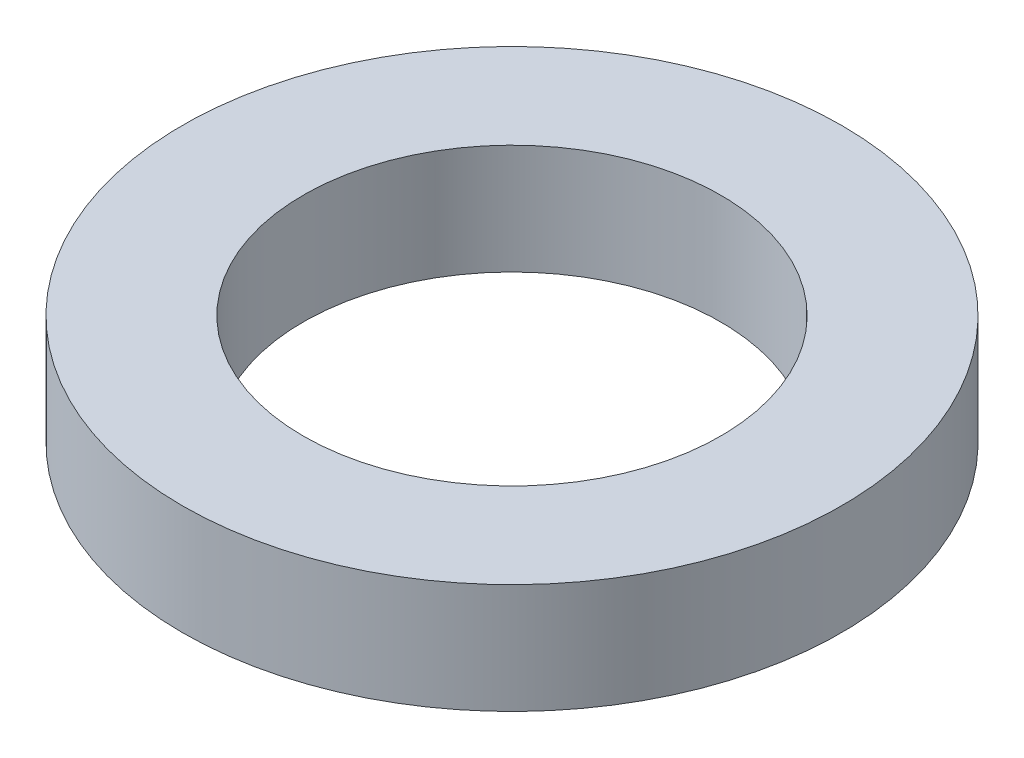
from build123d import *

# Parameters (mm, degrees)
SKETCH1_R           = 3
SKETCH1_R_2         = 1.9
BOSS_EXTRUDE1_DEPTH = 0.5


with BuildPart() as part:
    # Sketch1 → Boss-Extrude1 (new body, symmetric)
    with BuildSketch(Plane(origin=(0, 0, 0), x_dir=(1, 0, 0), z_dir=(0, 1, 0))):
        Circle(SKETCH1_R)
        Circle(SKETCH1_R_2, mode=Mode.SUBTRACT)
    extrude(amount=BOSS_EXTRUDE1_DEPTH, both=True)


solid = part.part
